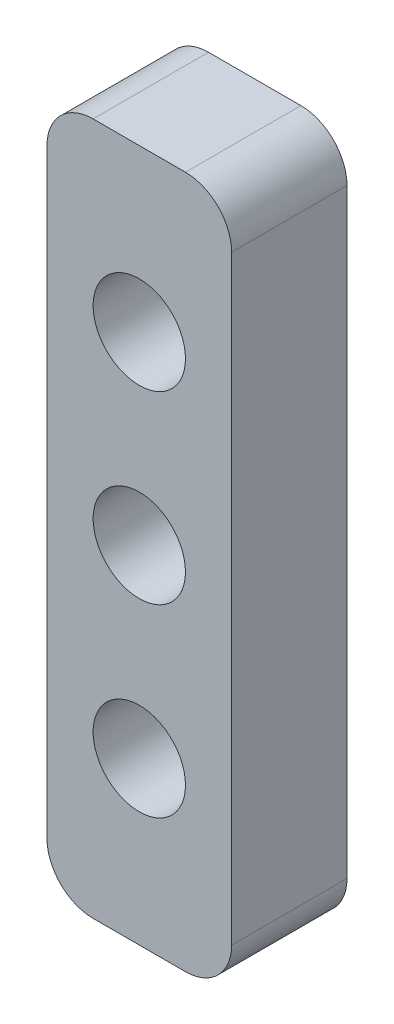
from build123d import *

# Parameters (mm, degrees)
BOSS_EXTRUDE1_DEPTH = 5
SKETCH3_R           = 2
CUT_EXTRUDE2_DEPTH  = 6


with BuildPart() as part:
    # Sketch1 → Boss-Extrude1 (new body)
    with BuildSketch(Plane.XY):
        with BuildLine():
            Line((0, -13), (0, 13))
            ThreePointArc((0, 13), (0.585786438, 14.414213562), (2, 15))
            Line((2, 15), (6, 15))
            ThreePointArc((6, 15), (7.414213562, 14.414213562), (8, 13))
            Line((8, 13), (8, -13))
            ThreePointArc((8, -13), (7.414213562, -14.414213562), (6, -15))
            Line((6, -15), (2, -15))
            ThreePointArc((2, -15), (0.585786438, -14.414213562), (0, -13))
        make_face()
    extrude(amount=BOSS_EXTRUDE1_DEPTH)

    # Sketch3 → Cut-Extrude2 (cut, through all)
    with BuildSketch(Plane.XY.offset(5)):
        with Locations((4, 0)):
            Circle(SKETCH3_R)
        with Locations((4, 8)):
            Circle(SKETCH3_R)
        with Locations((4, -8)):
            Circle(SKETCH3_R)
    extrude(amount=-CUT_EXTRUDE2_DEPTH, mode=Mode.SUBTRACT)


solid = part.part
